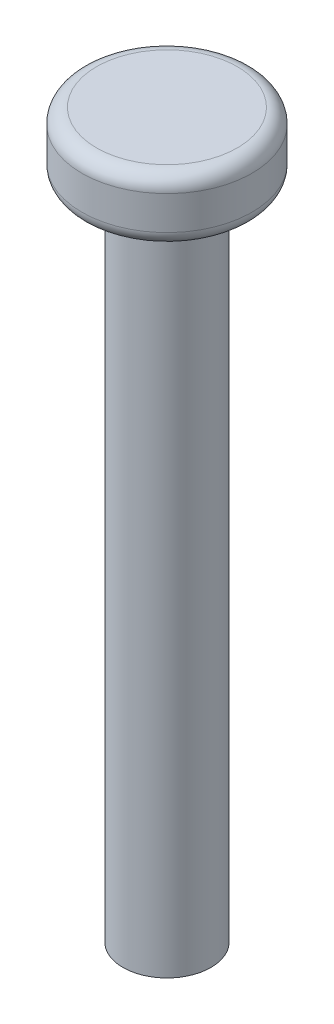
from build123d import *

# Parameters (mm, degrees)
SKETCH1_R           = 3
BOSS_EXTRUDE1_DEPTH = 45
SKETCH2_R           = 5.8
BOSS_EXTRUDE2_DEPTH = 4.3
FILLET1_R           = 1


with BuildPart() as part:
    # Sketch1 → Boss-Extrude1 (new body)
    with BuildSketch(Plane(origin=(0, 0, 0), x_dir=(1, 0, 0), z_dir=(0, 1, 0))):
        with Locations(Location((0, 0, 0), (0, 0, 270))):  # turned: the seam where the file's is
            Circle(SKETCH1_R)
    extrude(amount=BOSS_EXTRUDE1_DEPTH)

    # Sketch2 → Boss-Extrude2 (add)
    with BuildSketch(Plane(origin=(0, 45, 0), x_dir=(1, 0, 0), z_dir=(0, 1, 0))):
        with Locations(Location((0, 0, 0), (0, 0, 270))):  # turned: the seam where the file's is
            Circle(SKETCH2_R)
    extrude(amount=BOSS_EXTRUDE2_DEPTH)

    # Fillet1
    fillet1_edges = [part.edges().sort_by_distance(p)[0] for p in [
        (0, 45, -5.8),
        (0, 49.3, -5.8),
    ]]
    fillet(fillet1_edges, radius=FILLET1_R)


solid = part.part
